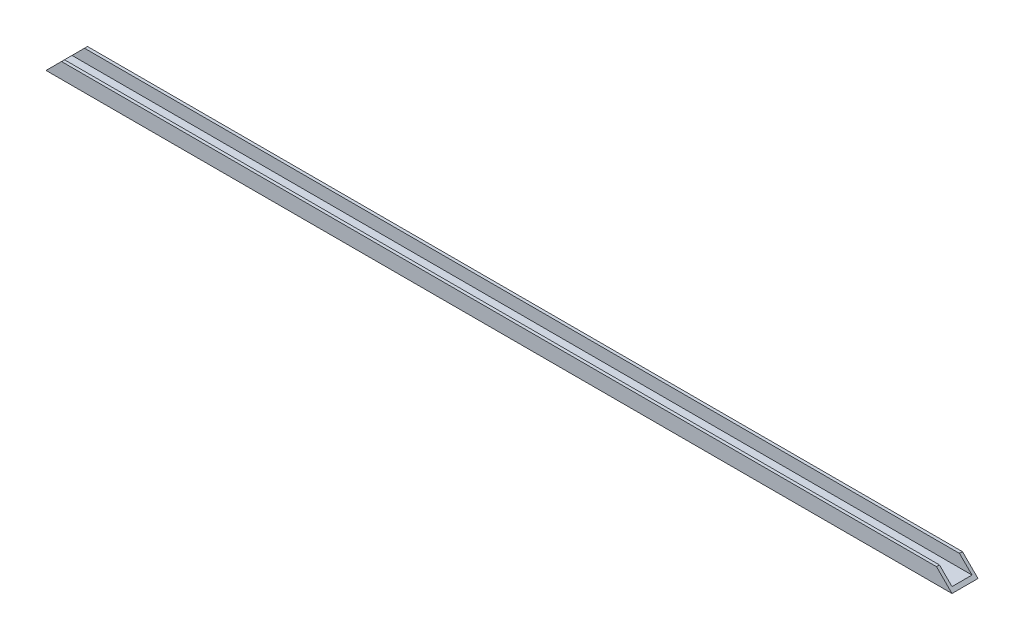
from build123d import *

# Parameters (mm, degrees)
BOSS_EXTRUDE1_DEPTH = 181.2
CUT_EXTRUDE1_DEPTH  = 11.4


with BuildPart() as part:
    # Sketch1 → Boss-Extrude1 (new body, symmetric)
    with BuildSketch(Plane(origin=(0, 0, 0), x_dir=(0, 0, -1), z_dir=(1, 0, 0))):
        Polygon((-4, 5), (-4, 0), (4, 0), (4, 5), (5.2, 5), (5.2, -1.2), (-5.2, -1.2), (-5.2, 5), align=None)
    extrude(amount=BOSS_EXTRUDE1_DEPTH, both=True)

    # Sketch3 → Cut-Extrude1 (cut, through all)
    with BuildSketch(Plane.XY.offset(5.2)):
        Polygon((-181.2, 5), (-181.2, -1.2), (-175, 5), align=None)
        Polygon((181.2, 5), (181.2, -1.2), (175, 5), align=None)
    extrude(amount=-CUT_EXTRUDE1_DEPTH, mode=Mode.SUBTRACT)


solid = part.part
